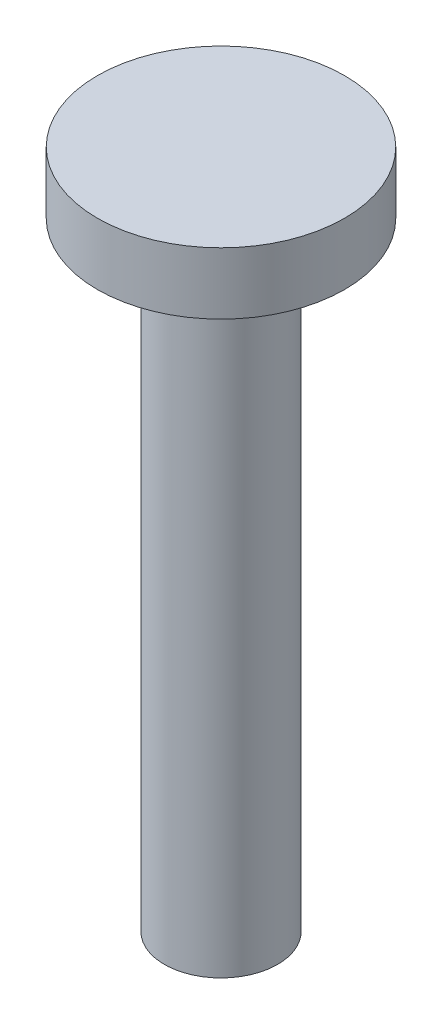
from build123d import *

# Parameters (mm, degrees)
SKETCH1_R           = 10
BOSS_EXTRUDE1_DEPTH = 90
SCALE_1_SCALE       = 0.3
SKETCH_1_R          = 6
EXTRUDE_1_DEPTH     = 3
SKETCH_2_R          = 3
EXTRUDE_3_DEPTH     = 3
SKETCH_3_R          = 3
SKETCH_3_R_2        = 2.75
CUT_EXTRUDE_2_DEPTH = 30


with BuildPart() as part:
    # Sketch1 → Boss-Extrude1 (new body)
    with BuildSketch(Plane(origin=(0, 0, 0), x_dir=(1, 0, 0), z_dir=(0, 1, 0))):
        Circle(SKETCH1_R)
    extrude(amount=BOSS_EXTRUDE1_DEPTH)


with BuildPart() as part_1:
    # 축척1: scaled about (0, 45, 0)
    add(part.part.scale(SCALE_1_SCALE).moved(Location((0, 31.5, 0))))

    # 스케치1 → 보스-돌출1 (add)
    with BuildSketch(Plane(origin=(0, 58.5, 0), x_dir=(1, 0, 0), z_dir=(0, 1, 0))):
        Circle(SKETCH_1_R)
    extrude(amount=EXTRUDE_1_DEPTH)

    # 스케치2 → 보스-돌출3 (add)
    with BuildSketch(Plane.XZ.offset(-31.5)):
        Circle(SKETCH_2_R)
    extrude(amount=EXTRUDE_3_DEPTH)

    # 스케치3 → 컷-돌출2 (cut)
    with BuildSketch(Plane.XZ.offset(-28.5)):
        Circle(SKETCH_3_R)
        Circle(SKETCH_3_R_2, mode=Mode.SUBTRACT)
    extrude(amount=-CUT_EXTRUDE_2_DEPTH, mode=Mode.SUBTRACT)


solid = part_1.part
